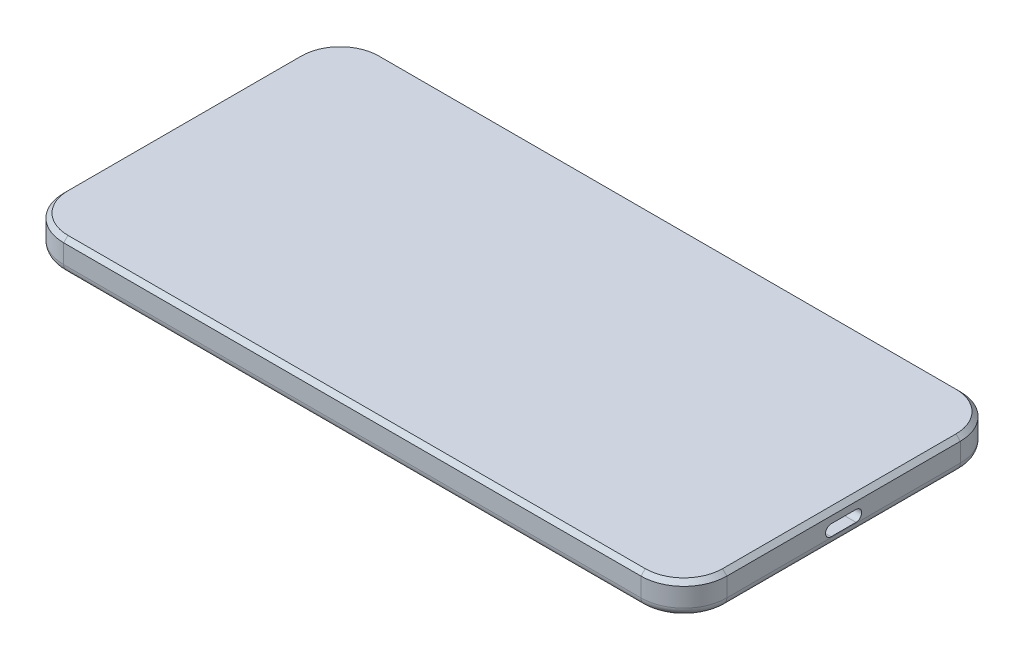
from build123d import *

# Parameters (mm, degrees)
SKETCH1_W           = 154.5
SKETCH1_H           = 74.4
BOSS_EXTRUDE1_DEPTH = 7.4
FILLET1_R           = 10
CHAMFER1_SIZE       = 1
FILLET2_R           = 2
SKETCH2_R           = 4.3
BOSS_EXTRUDE2_DEPTH = 0.6
CHAMFER2_SIZE       = 0.3
CUT_EXTRUDE1_DEPTH  = 6.75


with BuildPart() as part:
    # Sketch1 → Boss-Extrude1 (new body)
    with BuildSketch(Plane(origin=(0, 0, 0), x_dir=(1, 0, 0), z_dir=(0, 1, 0))):
        Rectangle(SKETCH1_W, SKETCH1_H)
    extrude(amount=BOSS_EXTRUDE1_DEPTH)

    # Fillet1
    fillet1_edges = [part.edges().sort_by_distance(p)[0] for p in [
        (77.25, 3.7, 37.2),
        (-77.25, 3.7, 37.2),
        (-77.25, 3.7, -37.2),
        (77.25, 3.7, -37.2),
    ]]
    fillet(fillet1_edges, radius=FILLET1_R)

    # Chamfer1
    chamfer1_edges = [part.edges().sort_by_distance(p)[0] for p in [
        (-77.25, 7.4, 0),
        (0, 7.4, -37.2),
        (77.25, 7.4, 0),
        (0, 7.4, 37.2),
        (74.321067812, 7.4, 34.271067812),
        (-74.321067812, 7.4, 34.271067812),
        (74.321067812, 7.4, -34.271067812),
        (-74.321067812, 7.4, -34.271067812),
    ]]
    chamfer(chamfer1_edges, length=CHAMFER1_SIZE)

    # Fillet2
    fillet2_edges = [part.edges().sort_by_distance(p)[0] for p in [
        (-77.25, 0, 0),
        (77.25, 0, 0),
        (0, 0, 37.2),
        (0, 0, -37.2),
        (74.321067812, 0, 34.271067812),
        (-74.321067812, 0, 34.271067812),
        (74.321067812, 0, -34.271067812),
        (-74.321067812, 0, -34.271067812),
    ]]
    fillet(fillet2_edges, radius=FILLET2_R)

    # Sketch2 → Boss-Extrude2 (add)
    with BuildSketch(Plane.XZ):
        with Locations((-68.95, -13.75)):
            Circle(SKETCH2_R)
        with BuildLine():
            Line((-73.25, -13.75), (-73.25, -23.65))
            ThreePointArc((-73.25, -23.65), (-68.95, -19.35), (-64.65, -23.65))
            Line((-64.65, -23.65), (-64.65, -13.75))
            ThreePointArc((-64.65, -13.75), (-68.95, -18.05), (-73.25, -13.75))
        make_face()
        with Locations((-68.95, -23.65)):
            Circle(SKETCH2_R)
    extrude(amount=BOSS_EXTRUDE2_DEPTH)

    # Chamfer2
    chamfer2_edges = [part.edges().sort_by_distance(p)[0] for p in [
        (-64.65, -0.6, -18.7),
        (-73.25, -0.6, -18.7),
        (-68.95, -0.6, -9.45),
        (-68.95, -0.6, -27.95),
    ]]
    chamfer(chamfer2_edges, length=CHAMFER2_SIZE)

    # Sketch3 → Cut-Extrude1 (cut)
    with BuildSketch(Plane(origin=(77.25, 0, 0), x_dir=(0, 0, -1), z_dir=(1, 0, 0))):
        with BuildLine():
            Line((-2.9, 4.8), (2.9, 4.8))
            ThreePointArc((2.9, 4.8), (4.2, 3.5), (2.9, 2.2))
            Line((2.9, 2.2), (-2.9, 2.2))
            ThreePointArc((-2.9, 2.2), (-4.2, 3.5), (-2.9, 4.8))
        make_face()
    extrude(amount=-CUT_EXTRUDE1_DEPTH, mode=Mode.SUBTRACT)


solid = part.part
